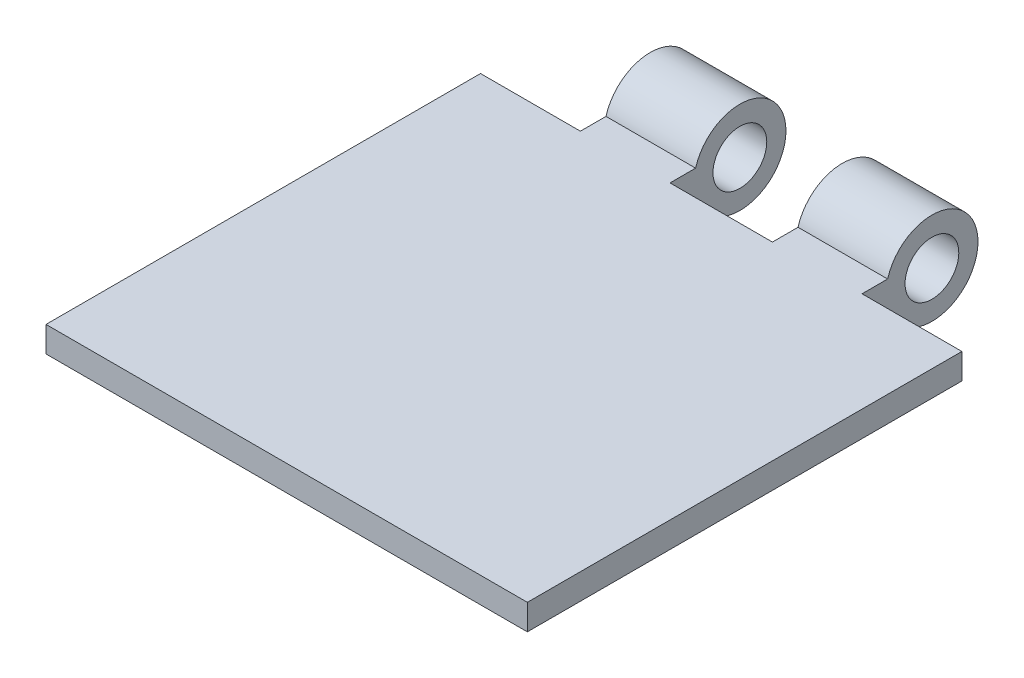
from build123d import *

# Parameters (mm, degrees)
SKETCH1_W               = 47.752
SKETCH1_H               = 40.64
BOSS_EXTRUDE1_DEPTH     = 2.54
SKETCH3_R               = 4.572
BOSS_EXTRUDE3_DEPTH     = 23.876
SKETCH7_W               = 10.16
SKETCH7_H               = 13.274102891
SKETCH7_W_2             = 10.953832873
SKETCH7_H_2             = 12.896384516
SKETCH7_W_3             = 11.331551248
CUT_EXTRUDE4_DEPTH      = 47.752
CUT_EXTRUDE4_DEPTH_BACK = 2.54
SKETCH8_W               = 47.752
SKETCH8_H               = 2.54
BOSS_EXTRUDE4_DEPTH     = 5.08
SKETCH9_R               = 2.667
CUT_EXTRUDE5_DEPTH      = 33.782


with BuildPart() as part:
    # Sketch1 → Boss-Extrude1 (new body)
    with BuildSketch(Plane(origin=(0, 0, 0), x_dir=(1, 0, 0), z_dir=(0, 1, 0))):
        Rectangle(SKETCH1_W, SKETCH1_H)
    extrude(amount=BOSS_EXTRUDE1_DEPTH)

    # Sketch3 → Boss-Extrude3 (add, symmetric)
    with BuildSketch(Plane(origin=(0, 0, 0), x_dir=(0, 0, -1), z_dir=(1, 0, 0))):
        with Locations((24.638, 1.27)):
            Circle(SKETCH3_R)
    extrude(amount=BOSS_EXTRUDE3_DEPTH, both=True)

    # Sketch7 → Cut-Extrude4 (cut, two sides)
    with BuildSketch(Plane(origin=(0, 0, -20.245929418), x_dir=(-1, 0, 0), z_dir=(0, 0, -1))) as cut_extrude4_sk:
        with Locations((0, 0.687607575)):
            Rectangle(SKETCH7_W, SKETCH7_H)
        with Locations((19.446916437, 0.498748388)):
            Rectangle(SKETCH7_W_2, SKETCH7_H_2)
        with Locations((-19.635775624, 0.687607575)):
            Rectangle(SKETCH7_W_3, SKETCH7_H)
    extrude(amount=CUT_EXTRUDE4_DEPTH, mode=Mode.SUBTRACT)
    extrude(cut_extrude4_sk.sketch, amount=-CUT_EXTRUDE4_DEPTH_BACK, mode=Mode.SUBTRACT)

    # Sketch8 → Boss-Extrude4 (add)
    with BuildSketch(Plane.XY.offset(20.32)):
        with Locations((0, 1.27)):
            Rectangle(SKETCH8_W, SKETCH8_H)
    extrude(amount=BOSS_EXTRUDE4_DEPTH)

    # Sketch9 → Cut-Extrude5 (cut)
    with BuildSketch(Plane(origin=(13.97, 0, 0), x_dir=(0, 0, -1), z_dir=(1, 0, 0))):
        with Locations(Location((24.638, 1.27, 0), (0, 0, 90))):  # turned: the seam where the file's is
            Circle(SKETCH9_R)
    extrude(amount=-CUT_EXTRUDE5_DEPTH, mode=Mode.SUBTRACT)


solid = part.part
